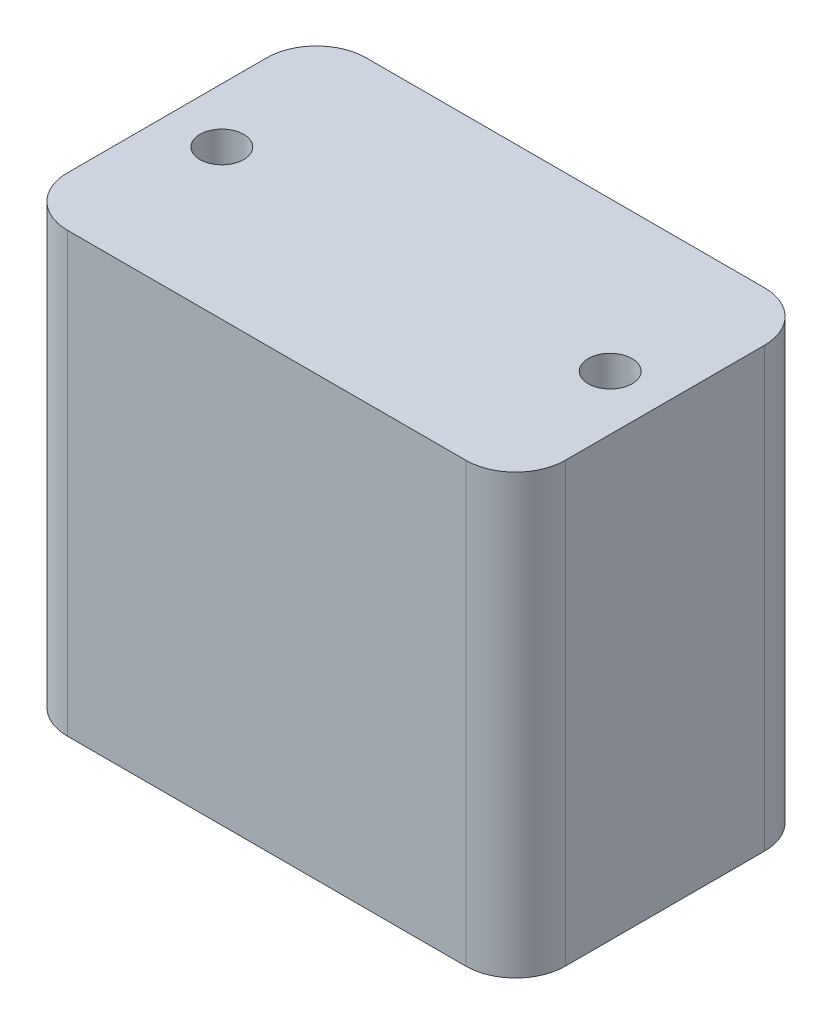
from build123d import *

# Parameters (mm, degrees)
SKETCH1_R           = 2.2
BOSS_EXTRUDE1_DEPTH = 44


with BuildPart() as part:
    # Sketch1 → Boss-Extrude1 (new body)
    with BuildSketch(Plane(origin=(0, 0, 0), x_dir=(1, 0, 0), z_dir=(0, 1, 0))):
        with BuildLine():
            Line((20, -15), (-20, -15))
            ThreePointArc((-20, -15), (-23.535533906, -13.535533906), (-25, -10))
            Line((-25, -10), (-25, 10))
            ThreePointArc((-25, 10), (-23.535533906, 13.535533906), (-20, 15))
            Line((-20, 15), (20, 15))
            ThreePointArc((20, 15), (23.535533906, 13.535533906), (25, 10))
            Line((25, 10), (25, -10))
            ThreePointArc((25, -10), (23.535533906, -13.535533906), (20, -15))
        make_face()
        with Locations((-19.5, 0)):
            Circle(SKETCH1_R, mode=Mode.SUBTRACT)
        with Locations((19.5, 0)):
            Circle(SKETCH1_R, mode=Mode.SUBTRACT)
    extrude(amount=BOSS_EXTRUDE1_DEPTH)


solid = part.part
